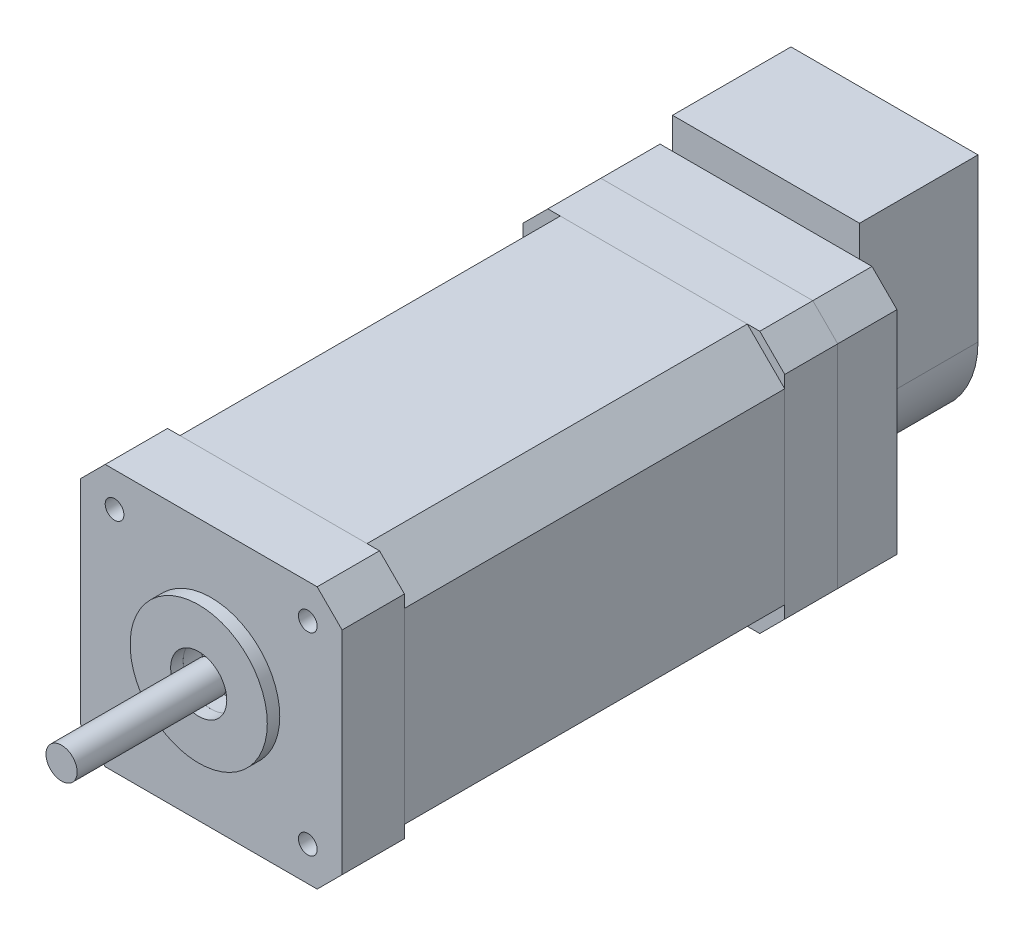
from build123d import *

# Parameters (mm, degrees)
SKETCH_1_W               = 42
SKETCH_1_H               = 42
EXTRUDE_1_DEPTH          = 30.5
CHAMFER_1_SIZE           = 6
SKETCH_15_W              = 42
SKETCH_15_H              = 42
EXTRUDE_11_DEPTH         = 10
SKETCH_16_W              = 42
SKETCH_16_H              = 42
EXTRUDE_12_DEPTH         = 8.5
SKETCH_17_W              = 42
SKETCH_17_H              = 42
EXTRUDE_13_DEPTH         = 9.5
CHAMFER_2_SIZE           = 4
CHAMFER_3_SIZE           = 4
CHAMFER_4_SIZE           = 4
SKETCH_2_R               = 11
EXTRUDE_2_DEPTH          = 2
SKETCH_3_R               = 4.5
CUT_EXTRUDE_1_DEPTH      = 5
SKETCH_6_R               = 2.5
EXTRUDE_9_DEPTH          = 24
EXTRUDE_10_DEPTH         = 19
SKETCH_8_R               = 1.5
CUT_EXTRUDE_3_DEPTH      = 4.5
PATTERN_CIRCULAR_1_COUNT = 4


with BuildPart() as part:
    # 草圖1 → 填料-伸長1 (new body, symmetric)
    with BuildSketch(Plane.XY):
        Rectangle(SKETCH_1_W, SKETCH_1_H)
    extrude(amount=EXTRUDE_1_DEPTH, both=True)

    # 導角1
    chamfer_1_edges = [part.edges().sort_by_distance(p)[0] for p in [
        (21, -21, 0),
        (-21, -21, 0),
        (-21, 21, 0),
        (21, 21, 0),
    ]]
    chamfer(chamfer_1_edges, length=CHAMFER_1_SIZE)


with BuildPart() as body_2:
    # 草圖15 → 填料-伸長11 (new body)
    with BuildSketch(Plane.XY.offset(30.5)):
        Rectangle(SKETCH_15_W, SKETCH_15_H)
    extrude(amount=EXTRUDE_11_DEPTH)

    # 導角2
    chamfer_2_edges = [body_2.edges().sort_by_distance(p)[0] for p in [
        (21, -21, 35.5),
        (-21, -21, 35.5),
        (-21, 21, 35.5),
        (21, 21, 35.5),
    ]]
    chamfer(chamfer_2_edges, length=CHAMFER_2_SIZE)


with BuildPart() as body_3:
    # 草圖16 → 填料-伸長12 (new body)
    with BuildSketch(Plane(origin=(0, 0, -30.5), x_dir=(-1, 0, 0), z_dir=(0, 0, -1))):
        Rectangle(SKETCH_16_W, SKETCH_16_H)
    extrude(amount=EXTRUDE_12_DEPTH)

    # 導角3
    chamfer_3_edges = [body_3.edges().sort_by_distance(p)[0] for p in [
        (-21, -21, -34.75),
        (21, -21, -34.75),
        (21, 21, -34.75),
        (-21, 21, -34.75),
    ]]
    chamfer(chamfer_3_edges, length=CHAMFER_3_SIZE)


with BuildPart() as body_4:
    # 草圖17 → 填料-伸長13 (new body)
    with BuildSketch(Plane.XY.offset(-39)):
        Rectangle(SKETCH_17_W, SKETCH_17_H)
    extrude(amount=-EXTRUDE_13_DEPTH)

    # 導角4
    chamfer_4_edges = [body_4.edges().sort_by_distance(p)[0] for p in [
        (21, -21, -43.75),
        (-21, -21, -43.75),
        (-21, 21, -43.75),
        (21, 21, -43.75),
    ]]
    chamfer(chamfer_4_edges, length=CHAMFER_4_SIZE)


with BuildPart() as body_5:
    # 草圖2 → 填料-伸長2 (new body)
    with BuildSketch(Plane.XY.offset(40.5)):
        Circle(SKETCH_2_R)
    extrude(amount=EXTRUDE_2_DEPTH)


with BuildPart() as cut_extrude_1_tool:
    # 草圖3 → 除料-伸長1 (new body)
    with BuildSketch(Plane.XY.offset(42.5)):
        Circle(SKETCH_3_R)
    extrude(amount=-CUT_EXTRUDE_1_DEPTH)


with BuildPart() as body_2_1:
    add(body_2.part)

    # 除料-伸長1: cut by cut_extrude_1_tool
    add(cut_extrude_1_tool.part, mode=Mode.SUBTRACT)

    # 草圖8 → 除料-伸長3 (cut)
    with BuildSketch(Plane.XY.offset(40.5)):
        with Locations((-15.5, 15.5)):
            Circle(SKETCH_8_R)
    cut_extrude_3 = extrude(amount=-CUT_EXTRUDE_3_DEPTH, mode=Mode.SUBTRACT)

    # 環狀複製排列1: 除料-伸長3 ×4 about axis
    pattern_circular_1_axis = Axis((0, 0, 0), (0, 0, 1))
    for i in range(1, PATTERN_CIRCULAR_1_COUNT):
        add(cut_extrude_3.rotate(pattern_circular_1_axis, i * 360 / PATTERN_CIRCULAR_1_COUNT), mode=Mode.SUBTRACT)


with BuildPart() as body_5_1:
    add(body_5.part)

    # 除料-伸長1: cut by cut_extrude_1_tool
    add(cut_extrude_1_tool.part, mode=Mode.SUBTRACT)


with BuildPart() as body_6:
    # 草圖6 → 填料-伸長9 (new body)
    with BuildSketch(Plane.XY.offset(40.5)):
        Circle(SKETCH_6_R)
    extrude(amount=EXTRUDE_9_DEPTH)


with BuildPart() as body_7:
    # 草圖9 → 填料-伸長10 (new body)
    with BuildSketch(Plane(origin=(0, 0, -48.5), x_dir=(-1, 0, 0), z_dir=(0, 0, -1))):
        with BuildLine():
            Line((-15, 0), (-15, 26))
            Line((-15, 26), (15, 26))
            Line((15, 26), (15, 0))
            ThreePointArc((15, 0), (0, -15), (-15, 0))
        make_face()
    extrude(amount=EXTRUDE_10_DEPTH)


solid = Compound([part.part, body_3.part, body_4.part, body_2_1.part, body_5_1.part, body_6.part, body_7.part])
